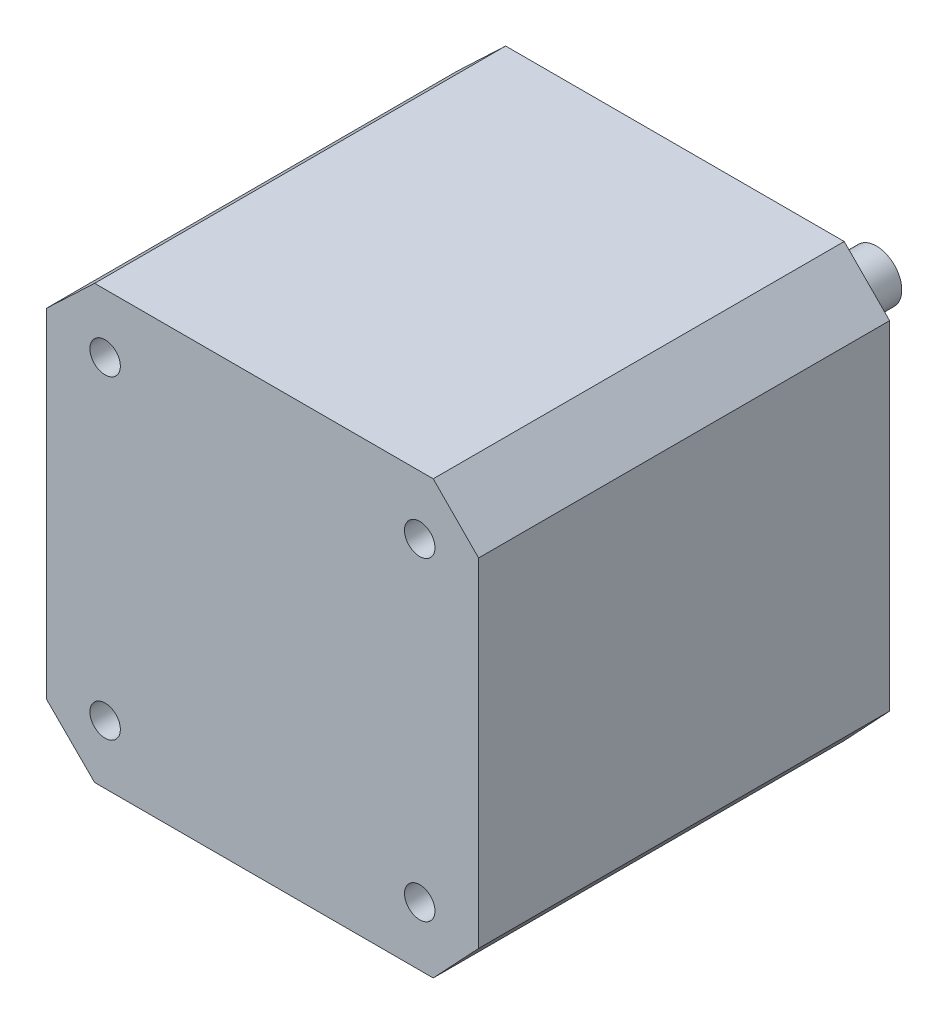
from build123d import *

# Parameters (mm, degrees)
SKETCH1_W      = 42.6
SKETCH1_H      = 42.6
SKETCH1_R      = 1.5
EXTRUDE1_DEPTH = 40.5
EXTRUDE2_DEPTH = 40.5
SKETCH5_R      = 11
EXTRUDE3_DEPTH = 2
SKETCH6_R      = 2.5
EXTRUDE4_DEPTH = 18


with BuildPart() as part:
    # Sketch1 → Extrude1 (new body)
    with BuildSketch(Plane.XY):
        with Locations((21.3, -4.1)):
            Rectangle(SKETCH1_W, SKETCH1_H)
        with Locations((5.8, 11.4)):
            Circle(SKETCH1_R, mode=Mode.SUBTRACT)
        with Locations((5.8, -19.6)):
            Circle(SKETCH1_R, mode=Mode.SUBTRACT)
        with Locations((36.8, -19.6)):
            Circle(SKETCH1_R, mode=Mode.SUBTRACT)
        with Locations((36.8, 11.4)):
            Circle(SKETCH1_R, mode=Mode.SUBTRACT)
    extrude(amount=EXTRUDE1_DEPTH)

    # Sketch2 → Extrude2 (cut)
    with BuildSketch(Plane(origin=(0, 0, 0), x_dir=(-1, 0, 0), z_dir=(0, 0, -1))):
        Polygon((-4.764447963, -25.4), (0, -20.64), (0, -25.4), align=None)
        Polygon((-4.764447963, 17.2), (0, 12.680245569), (0, 17.2), align=None)
        Polygon((-38.128194488, 17.2), (-42.6, 12.680245569), (-42.6, 17.2), align=None)
        Polygon((-38.128194488, -25.4), (-42.6, -20.64), (-42.6, -25.4), align=None)
    extrude(amount=-EXTRUDE2_DEPTH, mode=Mode.SUBTRACT)

    # Sketch5 → Extrude3 (add)
    with BuildSketch(Plane(origin=(0, 0, 0), x_dir=(-1, 0, 0), z_dir=(0, 0, -1))):
        with Locations((-21.3, -4.1)):
            Circle(SKETCH5_R)
    extrude(amount=EXTRUDE3_DEPTH)

    # Sketch6 → Extrude4 (add)
    with BuildSketch(Plane(origin=(0, 0, -2), x_dir=(-1, 0, 0), z_dir=(0, 0, -1))):
        with Locations((-21.3, -4.1)):
            Circle(SKETCH6_R)
    extrude(amount=EXTRUDE4_DEPTH)


solid = part.part
